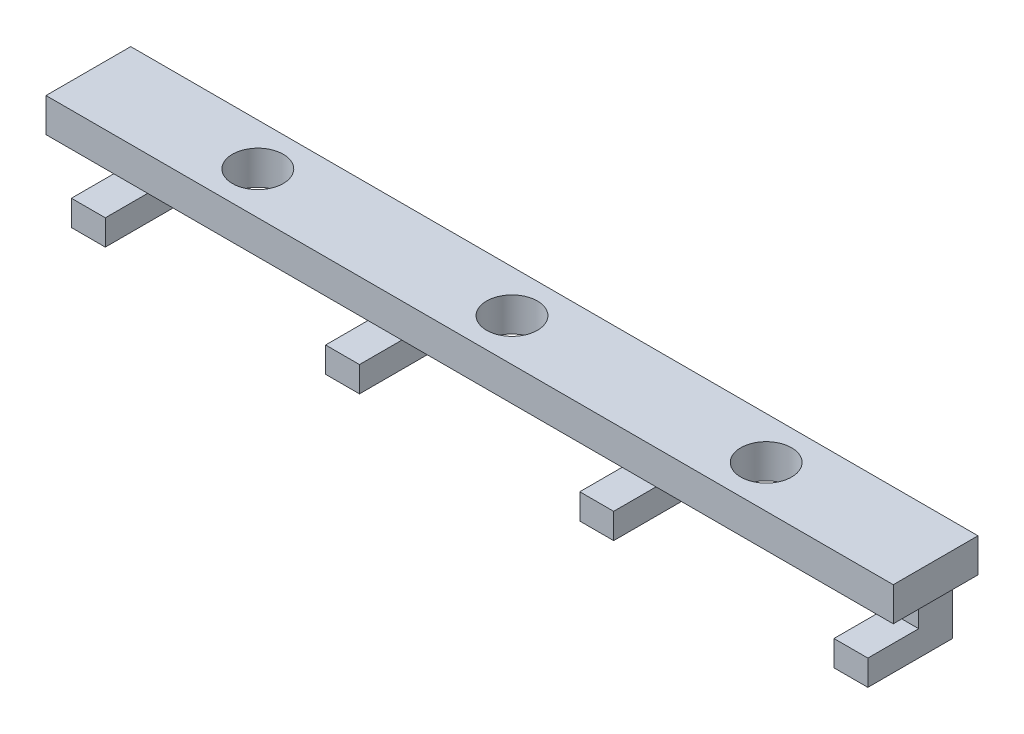
from build123d import *

# Parameters (mm, degrees)
SKETCH1_W           = 63.5
SKETCH1_H           = 6.35
SKETCH1_R           = 1.905
BOSS_EXTRUDE1_DEPTH = 2.54
SKETCH2_W           = 2.54
SKETCH2_H           = 6.35
BOSS_EXTRUDE2_DEPTH = 5.08
SKETCH3_W           = 63.5
SKETCH3_H           = 3.175
CUT_EXTRUDE1_DEPTH  = 3.81


with BuildPart() as part:
    # Sketch1 → Boss-Extrude1 (new body)
    with BuildSketch(Plane(origin=(0, 0, 0), x_dir=(1, 0, 0), z_dir=(0, 1, 0))):
        Rectangle(SKETCH1_W, SKETCH1_H)
        Circle(SKETCH1_R, mode=Mode.SUBTRACT)
        with Locations((-19.05, 0)):
            Circle(SKETCH1_R, mode=Mode.SUBTRACT)
        with Locations((19.05, 0)):
            Circle(SKETCH1_R, mode=Mode.SUBTRACT)
    extrude(amount=BOSS_EXTRUDE1_DEPTH)

    # Sketch2 → Boss-Extrude2 (add)
    with BuildSketch(Plane.XZ):
        with Locations((-9.525, 0)):
            Rectangle(SKETCH2_W, SKETCH2_H)
        with Locations((-28.575, 0)):
            Rectangle(SKETCH2_W, SKETCH2_H)
        with Locations((9.525, 0)):
            Rectangle(SKETCH2_W, SKETCH2_H)
        with Locations((28.575, 0)):
            Rectangle(SKETCH2_W, SKETCH2_H)
    extrude(amount=BOSS_EXTRUDE2_DEPTH)

    # Sketch3 → Cut-Extrude1 (cut)
    with BuildSketch(Plane.XY.offset(3.175)):
        with Locations((0, -1.5875)):
            Rectangle(SKETCH3_W, SKETCH3_H)
    extrude(amount=-CUT_EXTRUDE1_DEPTH, mode=Mode.SUBTRACT)


solid = part.part
